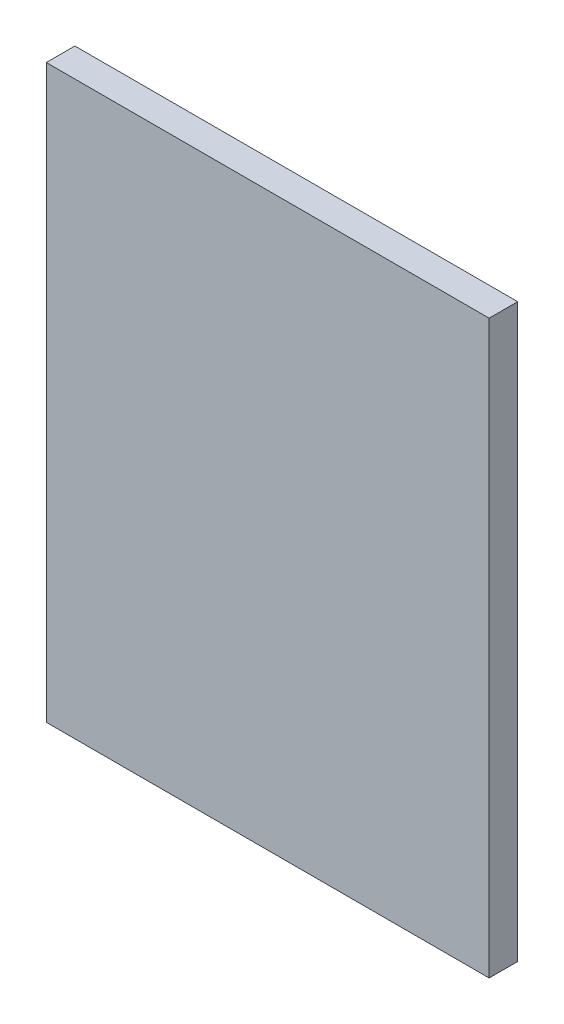
from build123d import *

# Parameters (mm, degrees)
SKETCH1_W                 = 155
SKETCH1_H                 = 200
BOTTOM_OUTER_CASING_DEPTH = 10


with BuildPart() as part:
    # Sketch1 → Bottom Outer Casing (new body)
    with BuildSketch(Plane.XY):
        with Locations((77.5, 100)):
            Rectangle(SKETCH1_W, SKETCH1_H)
    extrude(amount=BOTTOM_OUTER_CASING_DEPTH)


solid = part.part
